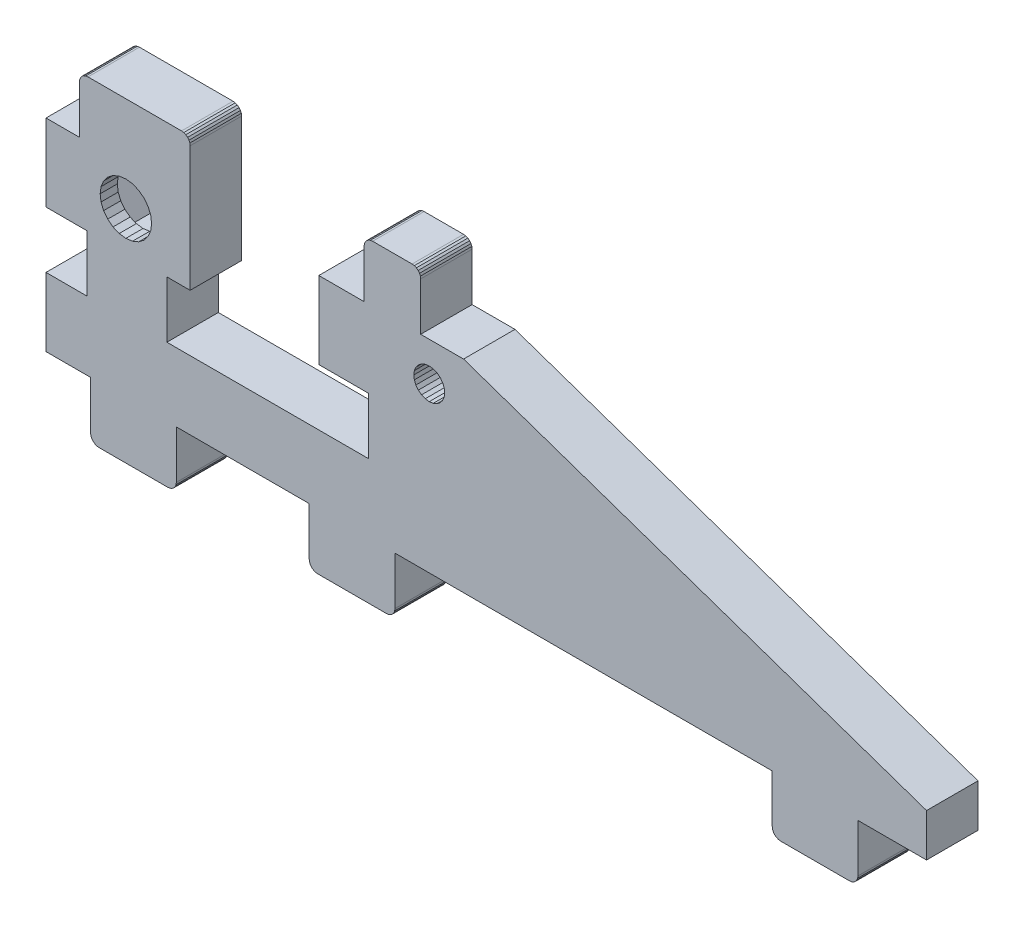
from build123d import *

# Parameters (mm, degrees)
BOSS_EXTRUDE1_DEPTH = 6
BOSS_EXTRUDE2_DEPTH = 2


with BuildPart() as part:
    # Sketch1 → Boss-Extrude1 (new body)
    with BuildSketch(Plane.XY):
        Polygon((-478.194997877, -284.039454162), (-470.194997877, -284.039454162), (-469.936178832, -284.005379989), (-469.694997877, -283.905479566), (-469.487891096, -283.746560944), (-469.328972474, -283.539454162), (-469.229072051, -283.298273207), (-469.194997877, -283.039454162), (-469.194997877, -277.439454162), (-425.194997877, -277.439454162), (-425.194997877, -283.039454162), (-425.160923704, -283.298273207), (-425.061023281, -283.539454162), (-424.902104659, -283.746560944), (-424.694997877, -283.905479566), (-424.453816922, -284.005379989), (-424.194997877, -284.039454162), (-416.194997877, -284.039454162), (-415.936178832, -284.005379989), (-415.694997877, -283.905479566), (-415.487891096, -283.746560944), (-415.328972474, -283.539454162), (-415.229072051, -283.298273207), (-415.194997877, -283.039454162), (-415.194997877, -277.439454162), (-407.194997877, -277.439454162), (-407.194997877, -272.439454162), (-461.194997877, -253.839454162), (-466.194997877, -253.839454162), (-466.194997877, -248.239454162), (-466.229072051, -247.980635117), (-466.328972474, -247.739454162), (-466.487891096, -247.532347381), (-466.694997877, -247.373428759), (-466.936178832, -247.273528336), (-467.194997877, -247.239454162), (-471.794997877, -247.239454162), (-472.053816922, -247.273528336), (-472.294997877, -247.373428759), (-472.502104659, -247.532347381), (-472.661023281, -247.739454162), (-472.760923704, -247.980635117), (-472.794997877, -248.239454162), (-472.794997877, -253.839454162), (-478.077534288, -253.839454162), (-478.077534288, -262.839454162), (-472.294997877, -262.839454162), (-472.294997877, -269.439454162), (-495.794997877, -269.439454162), (-495.794997877, -262.839454162), (-493.082722453, -262.839454162), (-493.082722453, -248.239454162), (-493.116796627, -247.980635117), (-493.21669705, -247.739454162), (-493.375615672, -247.532347381), (-493.582722453, -247.373428759), (-493.823903408, -247.273528336), (-494.082722453, -247.239454162), (-504.994997877, -247.239454162), (-505.253816922, -247.273528336), (-505.494997877, -247.373428759), (-505.702104659, -247.532347381), (-505.861023281, -247.739454162), (-505.960923704, -247.980635117), (-505.994997877, -248.239454162), (-505.994997877, -253.839454162), (-509.893267758, -253.839454162), (-509.893267758, -262.835675528), (-505.089806, -262.839454162), (-505.094997877, -269.439454162), (-509.893267758, -269.435677653), (-509.893267758, -277.439454162), (-504.694997877, -277.439454162), (-504.694997877, -283.039454162), (-504.660923704, -283.298273207), (-504.561023281, -283.539454162), (-504.402104659, -283.746560944), (-504.194997877, -283.905479566), (-503.953816922, -284.005379989), (-503.694997877, -284.039454162), (-495.694997877, -284.039454162), (-495.436178832, -284.005379989), (-495.194997877, -283.905479566), (-494.987891096, -283.746560944), (-494.828972474, -283.539454162), (-494.729072051, -283.298273207), (-494.694997877, -283.039454162), (-494.694997877, -277.439454162), (-479.194997877, -277.439454162), (-479.194997877, -283.039454162), (-479.160923704, -283.298273207), (-479.061023281, -283.539454162), (-478.902104659, -283.746560944), (-478.694997877, -283.905479566), (-478.453816922, -284.005379989), align=None)
        Polygon((-463.922205671, -257.066661956), (-463.636152151, -257.439454162), (-463.45633139, -257.873579881), (-463.394997877, -258.339454162), (-463.45633139, -258.805328444), (-463.636152151, -259.239454162), (-463.922205671, -259.612246369), (-464.294997877, -259.898299889), (-464.729123596, -260.07812065), (-465.194997877, -260.139454162), (-465.660872159, -260.07812065), (-466.094997877, -259.898299889), (-466.467790083, -259.612246369), (-466.753843604, -259.239454162), (-466.933664365, -258.805328444), (-466.994997877, -258.339454162), (-466.933664365, -257.873579881), (-466.753843604, -257.439454162), (-466.467790083, -257.066661956), (-466.094997877, -256.780608436), (-465.660872159, -256.600787675), (-465.194997877, -256.539454162), (-464.729123596, -256.600787675), (-464.294997877, -256.780608436), align=None, mode=Mode.SUBTRACT)
        Polygon((-503.1756105, -253.839454162), (-505.773686711, -258.339454162), (-503.1756105, -262.839454162), (-497.979458077, -262.839454162), (-495.381381866, -258.339454162), (-497.979458077, -253.839454162), align=None, mode=Mode.SUBTRACT)
    extrude(amount=-BOSS_EXTRUDE1_DEPTH)

    # Sketch1_4 → Boss-Extrude2 (add)
    with BuildSketch(Plane.XY):
        Polygon((-497.979458077, -262.839454162), (-495.381381866, -258.339454162), (-497.979458077, -253.839454162), (-503.1756105, -253.839454162), (-505.773686711, -258.339454162), (-503.1756105, -262.839454162), align=None)
        Polygon((-498.094928131, -254.039454162), (-503.060140446, -254.039454162), (-505.542746604, -258.339454162), (-503.060140446, -262.639454162), (-498.094928131, -262.639454162), (-495.612321973, -258.339454162), align=None, mode=Mode.SUBTRACT)
        Polygon((-495.612321973, -258.339454162), (-498.094928131, -254.039454162), (-503.060140446, -254.039454162), (-505.542746604, -258.339454162), (-503.060140446, -262.639454162), (-498.094928131, -262.639454162), align=None)
        Polygon((-498.210398185, -262.439454162), (-495.843262081, -258.339454162), (-498.210398185, -254.239454162), (-502.944670392, -254.239454162), (-505.311806496, -258.339454162), (-502.944670392, -262.439454162), align=None, mode=Mode.SUBTRACT)
        Polygon((-502.944670392, -262.439454162), (-498.210398185, -262.439454162), (-495.843262081, -258.339454162), (-498.210398185, -254.239454162), (-502.944670392, -254.239454162), (-505.311806496, -258.339454162), align=None)
        Polygon((-496.074202189, -258.339454162), (-498.325868239, -254.439454162), (-502.829200338, -254.439454162), (-505.080866388, -258.339454162), (-502.829200338, -262.239454162), (-498.325868239, -262.239454162), align=None, mode=Mode.SUBTRACT)
        Polygon((-498.325868239, -262.239454162), (-496.074202189, -258.339454162), (-498.325868239, -254.439454162), (-502.829200338, -254.439454162), (-505.080866388, -258.339454162), (-502.829200338, -262.239454162), align=None)
        Polygon((-496.305142296, -258.339454162), (-498.441338292, -254.639454162), (-502.713730284, -254.639454162), (-504.84992628, -258.339454162), (-502.713730284, -262.039454162), (-498.441338292, -262.039454162), align=None, mode=Mode.SUBTRACT)
        Polygon((-498.441338292, -262.039454162), (-496.305142296, -258.339454162), (-498.441338292, -254.639454162), (-502.713730284, -254.639454162), (-504.84992628, -258.339454162), (-502.713730284, -262.039454162), align=None)
        Polygon((-504.618986173, -258.339454162), (-502.598260231, -261.839454162), (-498.556808346, -261.839454162), (-496.536082404, -258.339454162), (-498.556808346, -254.839454162), (-502.598260231, -254.839454162), align=None, mode=Mode.SUBTRACT)
        Polygon((-502.598260231, -254.839454162), (-504.618986173, -258.339454162), (-502.598260231, -261.839454162), (-498.556808346, -261.839454162), (-496.536082404, -258.339454162), (-498.556808346, -254.839454162), align=None)
        Polygon((-502.482790177, -261.639454162), (-498.6722784, -261.639454162), (-496.767022512, -258.339454162), (-498.6722784, -255.039454162), (-502.482790177, -255.039454162), (-504.388046065, -258.339454162), align=None, mode=Mode.SUBTRACT)
        Polygon((-504.388046065, -258.339454162), (-502.482790177, -261.639454162), (-498.6722784, -261.639454162), (-496.767022512, -258.339454162), (-498.6722784, -255.039454162), (-502.482790177, -255.039454162), align=None)
        Polygon((-504.157105957, -258.339454162), (-502.367320123, -261.439454162), (-498.787748454, -261.439454162), (-496.99796262, -258.339454162), (-498.787748454, -255.239454162), (-502.367320123, -255.239454162), align=None, mode=Mode.SUBTRACT)
        Polygon((-502.367320123, -255.239454162), (-504.157105957, -258.339454162), (-502.367320123, -261.439454162), (-498.787748454, -261.439454162), (-496.99796262, -258.339454162), (-498.787748454, -255.239454162), align=None)
        Polygon((-503.475311767, -257.562997027), (-503.577534288, -258.339454162), (-503.475311767, -259.115911298), (-503.1756105, -259.839454162), (-502.698854632, -260.460774506), (-502.077534288, -260.937530374), (-501.353991424, -261.237231641), (-500.577534288, -261.339454162), (-499.801077153, -261.237231641), (-499.077534288, -260.937530374), (-498.456213945, -260.460774506), (-497.979458077, -259.839454162), (-497.67975681, -259.115911298), (-497.577534288, -258.339454162), (-497.67975681, -257.562997027), (-497.979458077, -256.839454162), (-498.456213945, -256.218133819), (-499.077534288, -255.741377951), (-499.801077153, -255.441676684), (-500.577534288, -255.339454162), (-501.353991424, -255.441676684), (-502.077534288, -255.741377951), (-502.698854632, -256.218133819), (-503.1756105, -256.839454162), align=None, mode=Mode.SUBTRACT)
    extrude(amount=-BOSS_EXTRUDE2_DEPTH)


solid = part.part
